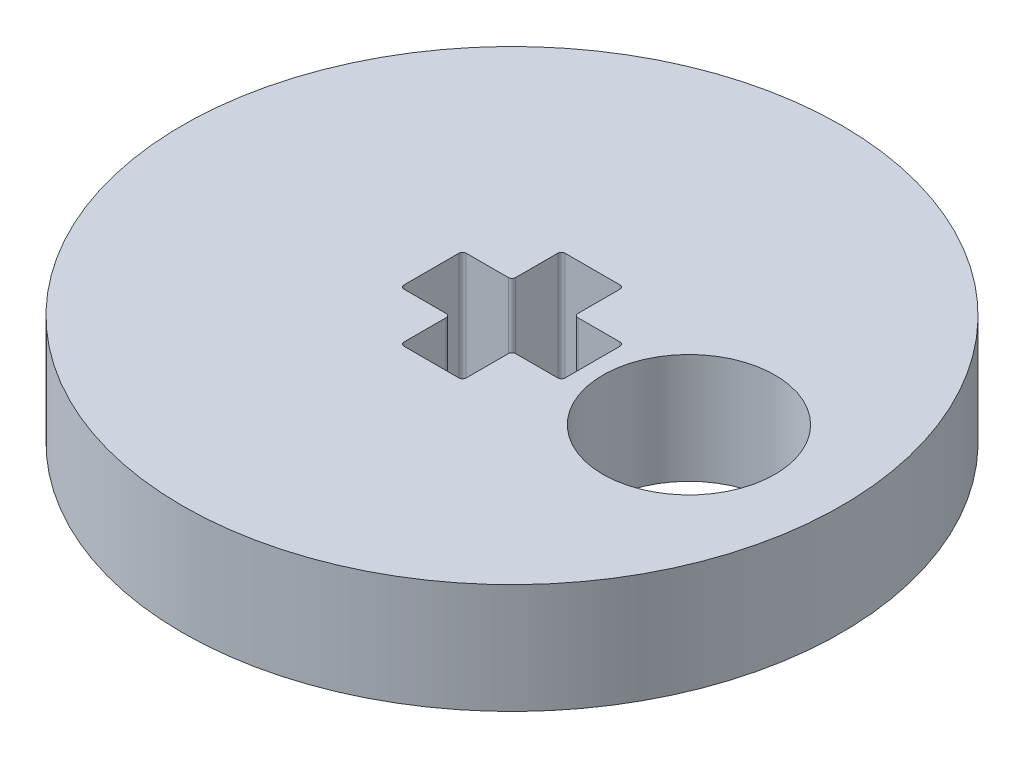
from build123d import *

# Parameters (mm, degrees)
SKETCH1_R           = 9
SKETCH1_R_2         = 2.35
BOSS_EXTRUDE1_DEPTH = 3
FILLET1_R           = 0.1


with BuildPart() as part:
    # Sketch1 → Boss-Extrude1 (new body)
    with BuildSketch(Plane(origin=(0, 0, 0), x_dir=(1, 0, 0), z_dir=(0, 1, 0))):
        Circle(SKETCH1_R)
        with Locations((4.997281989, -0.164841493)):
            Circle(SKETCH1_R_2, mode=Mode.SUBTRACT)
        Polygon((-2.2, 0.85), (-2.2, -0.85), (-0.85, -0.85), (-0.85, -2.2), (0.85, -2.2), (0.85, -0.85), (2.2, -0.85), (2.2, 0.85), (0.85, 0.85), (0.85, 2.2), (-0.85, 2.2), (-0.85, 0.85), align=None, mode=Mode.SUBTRACT)
    extrude(amount=BOSS_EXTRUDE1_DEPTH)

    # Fillet1
    fillet1_edges = [part.edges().sort_by_distance(p)[0] for p in [
        (-0.85, 1.5, -0.85),
        (-2.2, 1.5, -0.85),
        (-2.2, 1.5, 0.85),
        (-0.85, 1.5, 0.85),
        (-0.85, 1.5, 2.2),
        (0.85, 1.5, 2.2),
        (0.85, 1.5, 0.85),
        (2.2, 1.5, 0.85),
        (2.2, 1.5, -0.85),
        (0.85, 1.5, -0.85),
        (0.85, 1.5, -2.2),
        (-0.85, 1.5, -2.2),
    ]]
    fillet(fillet1_edges, radius=FILLET1_R)


solid = part.part
